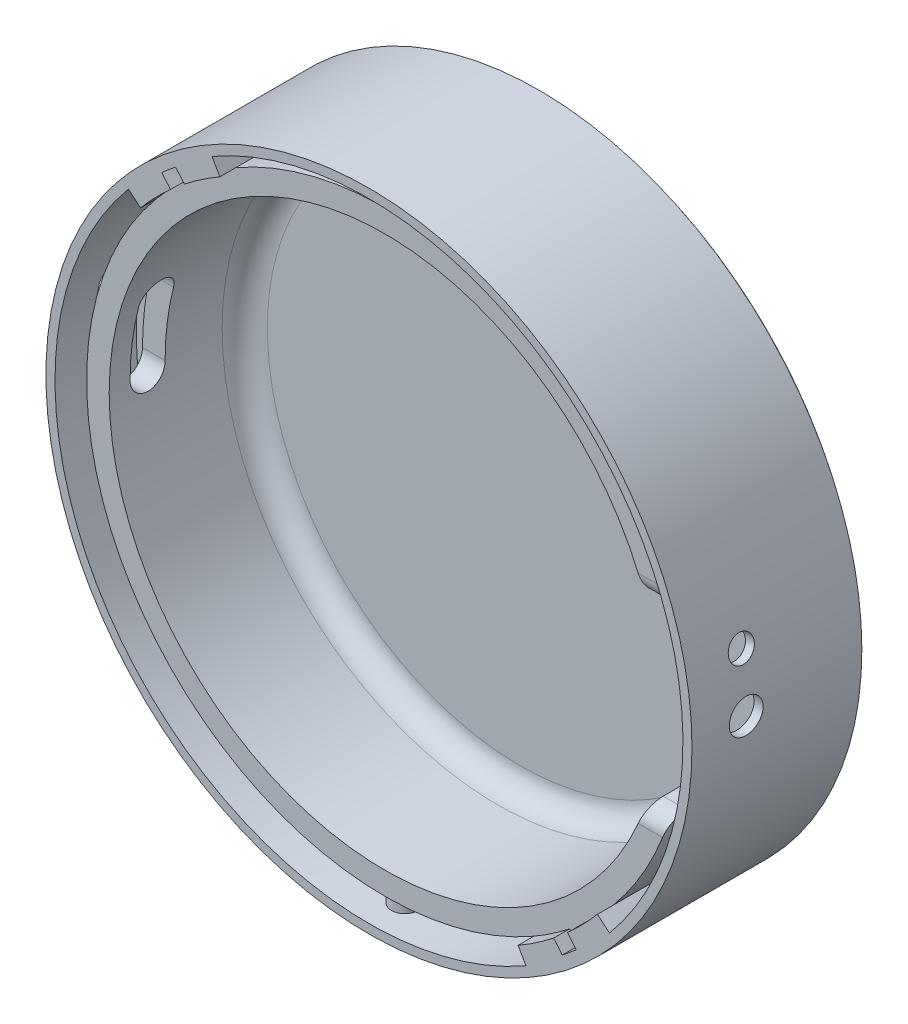
from build123d import *

# Parameters (mm, degrees)
CROQUIS1_R              = 75
SALIENTE_EXTRUIR1_DEPTH = 40
CROQUIS2_R              = 66
CORTAR_EXTRUIR1_DEPTH   = 3.5
CROQUIS3_R              = 61
CORTAR_EXTRUIR2_DEPTH   = 30
CROQUIS4_R              = 69.5
CROQUIS4_R_2            = 66
CORTAR_EXTRUIR3_DEPTH   = 18
CROQUIS5_R              = 3
SALIENTE_EXTRUIR2_DEPTH = 70
CROQUIS6_R              = 61
CORTAR_EXTRUIR4_DEPTH   = 30
REDONDEO1_R             = 10
REDONDEO2_R             = 5
CORTAR_EXTRUIR5_DEPTH   = 18
CROQUIS8_R              = 3.75
CORTAR_EXTRUIR6_DEPTH   = 96
CROQUIS10_R             = 2.85
CORTAR_EXTRUIR7_DEPTH   = 52
REDONDEO3_R             = 4
SALIENTE_EXTRUIR3_DEPTH = 22
CORTAR_EXTRUIR9_DEPTH   = 3.5
CROQUIS13_R             = 75
CROQUIS13_R_2           = 71.5
CORTAR_EXTRUIR10_DEPTH  = 61
ESCALA1_SCALE           = 0.8
CORTAR_EXTRUIR13_DEPTH  = 16


with BuildPart() as part:
    # Croquis1 → Saliente-Extruir1 (new body)
    with BuildSketch(Plane.XY):
        Circle(CROQUIS1_R)
    extrude(amount=-SALIENTE_EXTRUIR1_DEPTH)

    # Croquis2 → Cortar-Extruir1 (cut)
    with BuildSketch(Plane.XY):
        Circle(CROQUIS2_R)
    extrude(amount=-CORTAR_EXTRUIR1_DEPTH, mode=Mode.SUBTRACT)

    # Croquis3 → Cortar-Extruir2 (cut)
    with BuildSketch(Plane.XY.offset(-3.5)):
        Circle(CROQUIS3_R)
    extrude(amount=-CORTAR_EXTRUIR2_DEPTH, mode=Mode.SUBTRACT)

    # Croquis4 → Cortar-Extruir3 (cut)
    with BuildSketch(Plane.XY):
        Circle(CROQUIS4_R)
        Circle(CROQUIS4_R_2, mode=Mode.SUBTRACT)
    extrude(amount=-CORTAR_EXTRUIR3_DEPTH, mode=Mode.SUBTRACT)

    # Croquis5 → Saliente-Extruir2 (add, symmetric)
    with BuildSketch(Plane(origin=(0, 0, 0), x_dir=(1, 0, 0), z_dir=(0, 1, 0))):
        with Locations(Location((0, 8, 0), (0, 0, 90))):
            Circle(CROQUIS5_R)
    extrude(amount=SALIENTE_EXTRUIR2_DEPTH, both=True)

    # Croquis6 → Cortar-Extruir4 (cut)
    with BuildSketch(Plane.XY.offset(-3.5)):
        Circle(CROQUIS6_R)
    extrude(amount=-CORTAR_EXTRUIR4_DEPTH, mode=Mode.SUBTRACT)

    # Redondeo1
    redondeo1_edges = [part.edges().sort_by_distance(p)[0] for p in [
        (-75, 0, -40),
    ]]
    fillet(redondeo1_edges, radius=REDONDEO1_R)

    # Redondeo2
    redondeo2_edges = [part.edges().sort_by_distance(p)[0] for p in [
        (-61, 0, -33.5),
    ]]
    fillet(redondeo2_edges, radius=REDONDEO2_R)

    # Croquis7 → Cortar-Extruir5 (cut)
    with BuildSketch(Plane.XY):
        with BuildLine():
            Line((63.698154294, 20), (30, 20))
            Line((30, 20), (30, -20))
            Line((30, -20), (63.698154294, -20))
            ThreePointArc((63.698154294, -20), (66.76417348, 0), (63.698154294, 20))
        make_face()
    extrude(amount=-CORTAR_EXTRUIR5_DEPTH, mode=Mode.SUBTRACT)

    # Croquis8 → Cortar-Extruir6 (cut, symmetric)
    with BuildSketch(Plane(origin=(0, 0, 0), x_dir=(0, 0, -1), z_dir=(1, 0, 0))):
        with Locations(Location((12, 0, 0), (0, 0, 180))):
            Circle(CROQUIS8_R)
    extrude(amount=CORTAR_EXTRUIR6_DEPTH, both=True, mode=Mode.SUBTRACT)

    # Croquis10 → Cortar-Extruir7 (cut)
    with BuildSketch(Plane(origin=(73.860581476, 13.023613325, 0), x_dir=(0, 0, 1), z_dir=(0.9848077530122091, 0.17364817766692414, 0))):
        with Locations(Location((-12, 0, 0), (0, 0, 270))):
            Circle(CROQUIS10_R)
    extrude(amount=-CORTAR_EXTRUIR7_DEPTH, mode=Mode.SUBTRACT)

    # Redondeo3
    redondeo3_edges = [part.edges().sort_by_distance(p)[0] for p in [
        (60.262429455, 20, -3.5),
        (60.262429455, -20, -3.5),
        (60.262429455, -20, -18),
        (60.262429455, 20, -18),
    ]]
    fillet(redondeo3_edges, radius=REDONDEO3_R)

    # Croquis11 → Saliente-Extruir3 (add)
    with BuildSketch(Plane.XY):
        with BuildLine():
            Line((-35.631233767, 61.715107221), (-33, 57.15767665))
            ThreePointArc((-33, 57.15767665), (-42.423982239, 50.558933246), (-50.558933246, 42.423982239))
            Line((-50.558933246, 42.423982239), (-54.590217257, 45.806631166))
            ThreePointArc((-54.590217257, 45.806631166), (-45.806631166, 54.590217257), (-35.631233767, 61.715107221))
        make_face()
        with BuildLine():
            Line((50.558933246, -42.423982239), (54.590217257, -45.806631166))
            ThreePointArc((54.590217257, -45.806631166), (45.806631166, -54.590217257), (35.631233767, -61.715107221))
            Line((35.631233767, -61.715107221), (33, -57.15767665))
            ThreePointArc((33, -57.15767665), (42.423982239, -50.558933246), (50.558933246, -42.423982239))
        make_face()
    extrude(amount=-SALIENTE_EXTRUIR3_DEPTH)

    # Croquis12 → Cortar-Extruir9 (cut)
    with BuildSketch(Plane.XY):
        with BuildLine():
            Line((45.865798515, -51.549282503), (-42.801620742, 54.120432942))
            ThreePointArc((-42.801620742, 54.120432942), (-44.352345068, 52.857066575), (-45.865798515, 51.549282503))
            Line((-45.865798515, 51.549282503), (42.801620742, -54.120432942))
            ThreePointArc((42.801620742, -54.120432942), (44.352345068, -52.857066575), (45.865798515, -51.549282503))
        make_face()
    extrude(amount=-CORTAR_EXTRUIR9_DEPTH, mode=Mode.SUBTRACT)

    # Croquis13 → Cortar-Extruir10 (cut)
    with BuildSketch(Plane.XY):
        Circle(CROQUIS13_R)
        Circle(CROQUIS13_R_2, mode=Mode.SUBTRACT)
    extrude(amount=-CORTAR_EXTRUIR10_DEPTH, mode=Mode.SUBTRACT)


with BuildPart() as part_1:
    # Escala1: scaled about (-0.802673378, -0.002824171, -27.739174073)
    add(part.part.scale(ESCALA1_SCALE).moved(Location((-0.160534676, -0.000564834, -5.547834815))))

    # Croquis14 → Cortar-Extruir13 (cut)
    with BuildSketch(Plane(origin=(-57.5, 0, 0), x_dir=(0, 0, -1), z_dir=(1, 0, 0))):
        with BuildLine():
            Line((12.047943745, 11.999421512), (12.047943745, -0.000578488))
            ThreePointArc((12.047943745, -0.000578488), (15.147943745, -3.100578488), (18.247943745, -0.000578488))
            Line((18.247943745, -0.000578488), (18.247943745, 11.999421512))
            ThreePointArc((18.247943745, 11.999421512), (15.147943745, 15.099421512), (12.047943745, 11.999421512))
        make_face()
    extrude(amount=CORTAR_EXTRUIR13_DEPTH, mode=Mode.SUBTRACT)


solid = part_1.part
